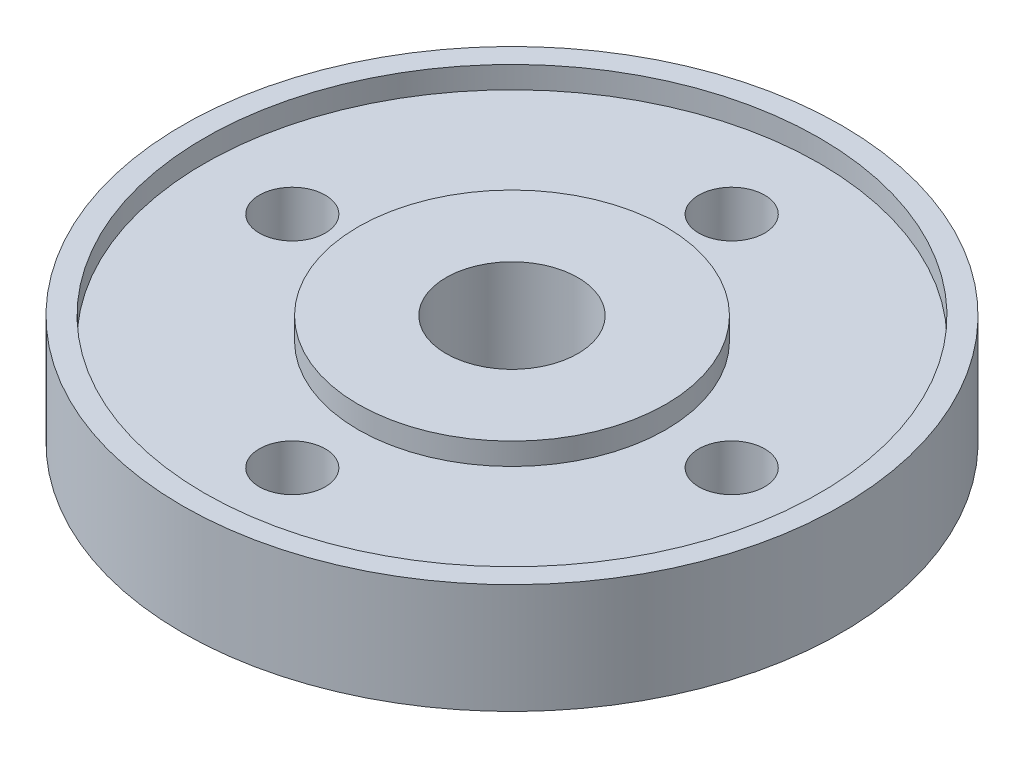
from build123d import *

# Parameters (mm, degrees)
SKETCH1_R                 = 15
SKETCH1_R_2               = 3
BOSS_EXTRUDE1_DEPTH       = 2.5
F_3_0MM_DOWEL_HOLE1_D     = 3
F_3_0MM_DOWEL_HOLE1_DEPTH = 5.001
CIRPATTERN1_COUNT         = 4
SKETCH6_R                 = 14
SKETCH6_R_2               = 7
CUT_EXTRUDE1_DEPTH        = 1


with BuildPart() as part:
    # Sketch1 → Boss-Extrude1 (new body, symmetric)
    with BuildSketch(Plane(origin=(0, 0, 0), x_dir=(1, 0, 0), z_dir=(0, 1, 0))):
        Circle(SKETCH1_R)
        Circle(SKETCH1_R_2, mode=Mode.SUBTRACT)
    extrude(amount=BOSS_EXTRUDE1_DEPTH, both=True)

    # Ø3.0mm Dowel Hole1
    with Locations(Plane(origin=(0, 2.5, 0), x_dir=(1, 0, 0), z_dir=(0, 1, 0))):
        with Locations((0, 10)):
            f_3_0mm_dowel_hole1 = Hole(F_3_0MM_DOWEL_HOLE1_D / 2, depth=F_3_0MM_DOWEL_HOLE1_DEPTH)

    # CirPattern1: Ø3.0mm Dowel Hole1 ×4 about axis
    cirpattern1_axis = Axis((0, 0, 0), (0, 1, 0))
    for i in range(1, CIRPATTERN1_COUNT):
        add(f_3_0mm_dowel_hole1.rotate(cirpattern1_axis, i * 360 / CIRPATTERN1_COUNT), mode=Mode.SUBTRACT)

    # Sketch6 → Cut-Extrude1 (cut)
    with BuildSketch(Plane(origin=(0, 2.5, 0), x_dir=(1, 0, 0), z_dir=(0, 1, 0))):
        Circle(SKETCH6_R)
        Circle(SKETCH6_R_2, mode=Mode.SUBTRACT)
    cut_extrude1 = extrude(amount=-CUT_EXTRUDE1_DEPTH, mode=Mode.SUBTRACT)

    # Mirror1: Cut-Extrude1 across plane
    add(cut_extrude1.mirror(Plane.ZX), mode=Mode.SUBTRACT)


solid = part.part
